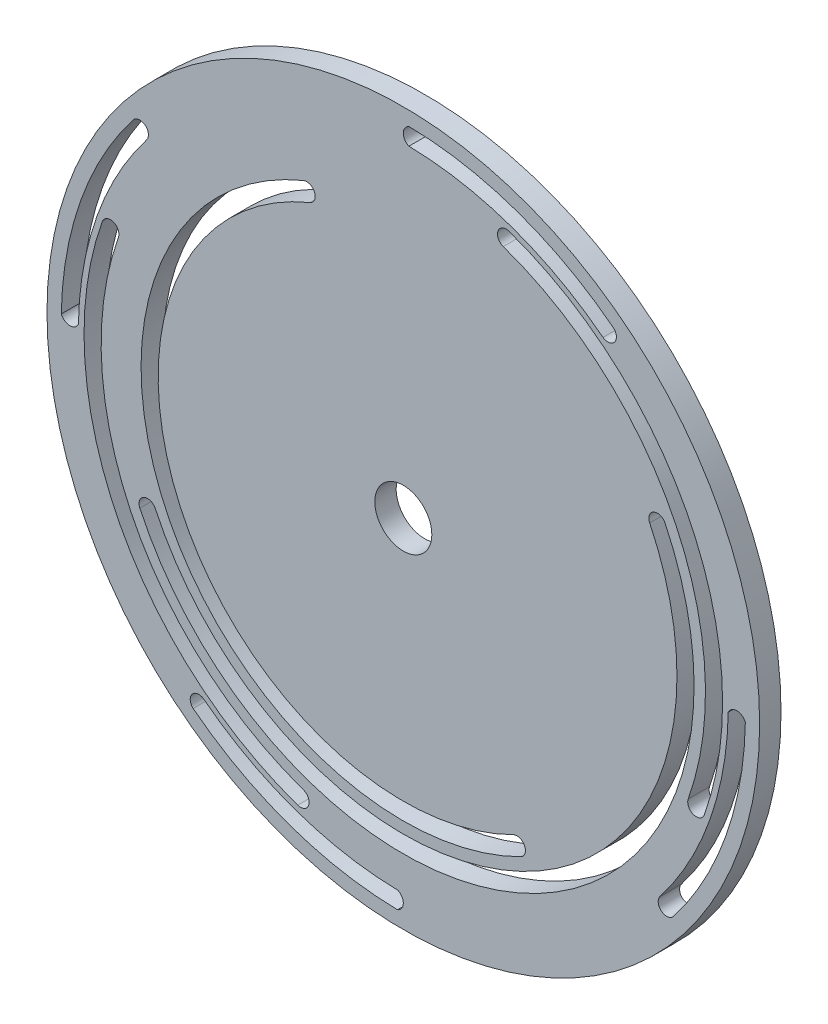
from build123d import *

# Parameters (mm, degrees)
CROQUIS1_R              = 50
CROQUIS1_R_2            = 4
SALIENTE_EXTRUIR3_DEPTH = 3


with BuildPart() as part:
    # Croquis1 → Saliente-Extruir3 (new body)
    with BuildSketch(Plane.XY):
        Circle(CROQUIS1_R)
        Circle(CROQUIS1_R_2, mode=Mode.SUBTRACT)
        with BuildLine():
            ThreePointArc((0.780784951, 45.593315024), (0.000190465, 46.806858641), (0.821878896, 47.992963183))
            ThreePointArc((0.821878896, 47.992963183), (15.980042003, 45.261885263), (29.492838566, 37.870469674))
            ThreePointArc((29.492838566, 37.870469674), (29.647643774, 36.228936164), (28.018196638, 35.97694619))
            ThreePointArc((28.018196638, 35.97694619), (15.181039903, 42.998791), (0.780784951, 45.593315024))
        make_face(mode=Mode.SUBTRACT)
        with BuildLine():
            ThreePointArc((35.97694619, -28.018196638), (42.998791, -15.181039903), (45.593315024, -0.780784951))
            ThreePointArc((45.593315024, -0.780784951), (46.806858641, -0.000190465), (47.992963183, -0.821878896))
            ThreePointArc((47.992963183, -0.821878896), (45.261885263, -15.980042003), (37.870469674, -29.492838566))
            ThreePointArc((37.870469674, -29.492838566), (36.228936164, -29.647643774), (35.97694619, -28.018196638))
        make_face(mode=Mode.SUBTRACT)
        with BuildLine():
            ThreePointArc((-28.018196638, -35.97694619), (-15.181039903, -42.998791), (-0.780784951, -45.593315024))
            ThreePointArc((-0.780784951, -45.593315024), (-0.000190465, -46.806858641), (-0.821878896, -47.992963183))
            ThreePointArc((-0.821878896, -47.992963183), (-15.980042003, -45.261885263), (-29.492838566, -37.870469674))
            ThreePointArc((-29.492838566, -37.870469674), (-29.647643774, -36.228936164), (-28.018196638, -35.97694619))
        make_face(mode=Mode.SUBTRACT)
        with BuildLine():
            ThreePointArc((-35.97694619, 28.018196638), (-42.998791, 15.181039903), (-45.593315024, 0.780784951))
            ThreePointArc((-45.593315024, 0.780784951), (-46.806858641, 0.000190465), (-47.992963183, 0.821878896))
            ThreePointArc((-47.992963183, 0.821878896), (-45.261885263, 15.980042003), (-37.870469674, 29.492838566))
            ThreePointArc((-37.870469674, 29.492838566), (-36.228936164, 29.647643774), (-35.97694619, 28.018196638))
        make_face(mode=Mode.SUBTRACT)
        with BuildLine():
            ThreePointArc((42.238881445, -14.930401679), (40.398847807, 19.364222056), (14.817024573, 42.27878644))
            ThreePointArc((14.817024573, 42.27878644), (13.287672492, 41.543203533), (14.023255399, 40.013851452))
            ThreePointArc((14.023255399, 40.013851452), (38.234623818, 18.326853017), (39.976084224, -14.130558732))
            ThreePointArc((39.976084224, -14.130558732), (40.707561361, -15.661878816), (42.238881445, -14.930401679))
        make_face(mode=Mode.SUBTRACT)
        with BuildLine():
            ThreePointArc((-39.976084224, 14.130558732), (-38.234623818, -18.326853017), (-14.023255399, -40.013851452))
            ThreePointArc((-14.023255399, -40.013851452), (-13.287672492, -41.543203533), (-14.817024573, -42.27878644))
            ThreePointArc((-14.817024573, -42.27878644), (-40.398847807, -19.364222056), (-42.238881445, 14.930401679))
            ThreePointArc((-42.238881445, 14.930401679), (-40.707561361, 15.661878816), (-39.976084224, 14.130558732))
        make_face(mode=Mode.SUBTRACT)
        with BuildLine():
            ThreePointArc((-36.967560027, -17.263820715), (17.510315589, -36.851442957), (36.733682313, 17.756029503))
            ThreePointArc((36.733682313, 17.756029503), (35.13104373, 18.314195762), (34.572877471, 16.711557179))
            ThreePointArc((34.572877471, 16.711557179), (16.480297025, -34.683711018), (-34.792997672, -16.248301849))
            ThreePointArc((-34.792997672, -16.248301849), (-36.388038282, -15.668780105), (-36.967560027, -17.263820715))
        make_face(mode=Mode.SUBTRACT)
        with BuildLine():
            ThreePointArc((-14.023255399, 34.023349453), (-33.48596426, -15.262050897), (16.480297025, -32.903492368))
            ThreePointArc((16.480297025, -32.903492368), (17.015836003, -31.293151409), (15.405495045, -30.75761243))
            ThreePointArc((15.405495045, -30.75761243), (-31.302097025, -14.266699752), (-13.108695264, 31.804435358))
            ThreePointArc((-13.108695264, 31.804435358), (-12.456518284, 33.371172473), (-14.023255399, 34.023349453))
        make_face(mode=Mode.SUBTRACT)
    extrude(amount=SALIENTE_EXTRUIR3_DEPTH)


solid = part.part
